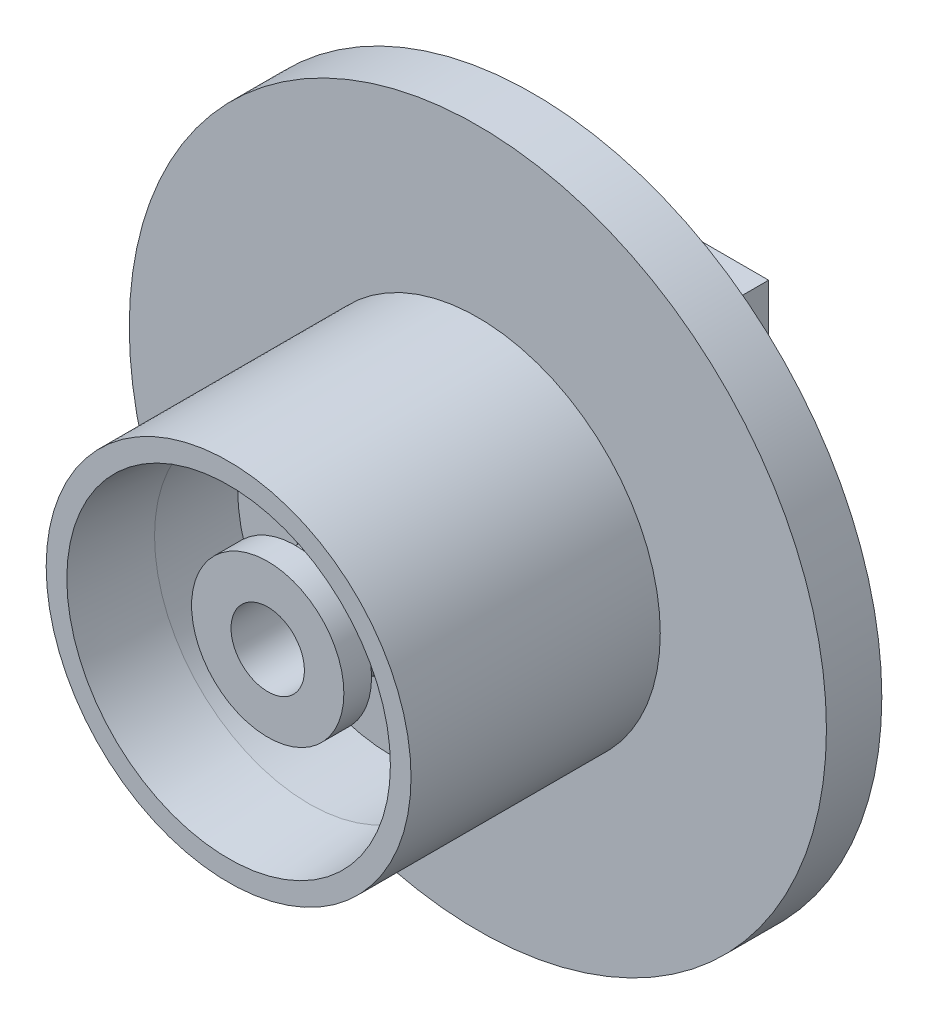
from build123d import *

# Parameters (mm, degrees)
BOSS_EXTRUDE1_START = 1
SKETCH3_W           = 20
SKETCH3_H           = 30
SKETCH3_R           = 2.65
BOSS_EXTRUDE1_DEPTH = 4
BOSS_EXTRUDE3_START = 1
SKETCH3_4_R         = 3.875
SKETCH3_4_R_2       = 2.65
BOSS_EXTRUDE3_DEPTH = 10
SKETCH3_5_R         = 5.5
SKETCH3_5_R_2       = 3.875
BOSS_EXTRUDE4_DEPTH = 1
SKETCH4_R           = 3.875
SKETCH4_R_2         = 2.65
BOSS_EXTRUDE5_DEPTH = 9.775
SKETCH4_3_R         = 5.5
SKETCH4_3_R_2       = 3.875
SKETCH4_3_R_3       = 2.65
BOSS_EXTRUDE6_DEPTH = 2


with BuildPart() as part:
    # Sketch2 → Revolve1 (revolve)
    with BuildSketch(Plane(origin=(0, 0, 0), x_dir=(1, 0, 0), z_dir=(0, 1, 0))):
        Polygon((11.175, 0), (11.175, -5), (7, -9.175), (7, -10.175), (11.175, -10.175), (11.175, -16.175), (11.684621465, -22), (13.175, -22), (13.175, -4), (25.175, -4), (25.175, 0), align=None)
    revolve(axis=Axis((0, 0, 0), (0, 0, 1)))


with BuildPart() as body_2:
    # Sketch3 → Boss-Extrude1 (new body)
    with BuildSketch(Plane(origin=(0, 0, -2), x_dir=(-1, 0, 0), z_dir=(0, 0, -1)).offset(BOSS_EXTRUDE1_START)):
        Rectangle(SKETCH3_W, SKETCH3_H)
        Circle(SKETCH3_R, mode=Mode.SUBTRACT)
    extrude(amount=BOSS_EXTRUDE1_DEPTH)

    # Sketch3_4 → Boss-Extrude3 (add)
    with BuildSketch(Plane(origin=(0, 0, -2), x_dir=(-1, 0, 0), z_dir=(0, 0, -1)).offset(BOSS_EXTRUDE3_START)):
        Circle(SKETCH3_4_R)
        Circle(SKETCH3_4_R_2, mode=Mode.SUBTRACT)
    extrude(amount=-BOSS_EXTRUDE3_DEPTH)

    # Sketch3_5 → Boss-Extrude4 (add)
    with BuildSketch(Plane(origin=(0, 0, -2), x_dir=(-1, 0, 0), z_dir=(0, 0, -1))):
        Circle(SKETCH3_5_R)
        Circle(SKETCH3_5_R_2, mode=Mode.SUBTRACT)
    extrude(amount=BOSS_EXTRUDE4_DEPTH)


with BuildPart() as body_3:
    # Sketch4 → Boss-Extrude5 (new body)
    with BuildSketch(Plane.XY.offset(17.175)):
        Circle(SKETCH4_R)
        Circle(SKETCH4_R_2, mode=Mode.SUBTRACT)
    extrude(amount=-BOSS_EXTRUDE5_DEPTH)

    # Sketch4_3 → Boss-Extrude6 (add)
    with BuildSketch(Plane.XY.offset(17.175)):
        Circle(SKETCH4_3_R)
        Circle(SKETCH4_3_R_2, mode=Mode.SUBTRACT)
        Circle(SKETCH4_3_R_2)
        Circle(SKETCH4_3_R_3, mode=Mode.SUBTRACT)
    extrude(amount=BOSS_EXTRUDE6_DEPTH)


solid = Compound([part.part, body_2.part, body_3.part])
